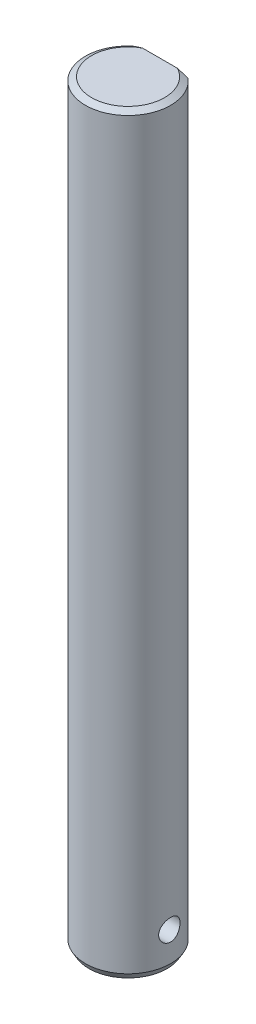
from build123d import *

# Parameters (mm, degrees)
SKETCH1_R             = 6
BOSS_EXTRUDE1_DEPTH   = 106
SKETCH2_W             = 13.926547721
SKETCH2_H             = 4.090447759
CUT_EXTRUDE1_DEPTH    = 10
SKETCH3_R             = 1.5
CUT_EXTRUDE2_DEPTH    = 10
CHAMFER1_SIZE         = 0.5
CHAMFER1_SIZE2        = 0.866025404
CHAMFER1_PART_2_SIZE  = 0.5
CHAMFER1_PART_2_SIZE2 = 0.866025404


with BuildPart() as part:
    # Sketch1 → Boss-Extrude1 (new body)
    with BuildSketch(Plane(origin=(0, 0, 0), x_dir=(1, 0, 0), z_dir=(0, 1, 0))):
        Circle(SKETCH1_R)
    extrude(amount=BOSS_EXTRUDE1_DEPTH)

    # Sketch2 → Cut-Extrude1 (cut)
    with BuildSketch(Plane(origin=(0, 106, 0), x_dir=(1, 0, 0), z_dir=(0, 1, 0))):
        with Locations((0.543038745, 6.545223879)):
            Rectangle(SKETCH2_W, SKETCH2_H)
    extrude(amount=-CUT_EXTRUDE1_DEPTH, mode=Mode.SUBTRACT)

    # Sketch3 → Cut-Extrude2 (cut, symmetric)
    with BuildSketch(Plane(origin=(0, 0, 0), x_dir=(0, 0, -1), z_dir=(1, 0, 0))):
        with Locations((0, 5)):
            Circle(SKETCH3_R)
    extrude(amount=CUT_EXTRUDE2_DEPTH, both=True, mode=Mode.SUBTRACT)

    # Chamfer1
    chamfer1_edges = [part.edges().sort_by_distance(p)[0] for p in [
        (-6, 0, 0),
    ]]
    chamfer1_side = [part.faces().sort_by_distance(p)[0] for p in [
        (0, 0, 0),
    ]]
    chamfer(chamfer1_edges, length=CHAMFER1_SIZE, length2=CHAMFER1_SIZE2, reference=chamfer1_side[0])

    # Chamfer1 part 2
    chamfer1_part_2_edges = [part.edges().sort_by_distance(p)[0] for p in [
        (-2.468626967, 106, 5.468626967),
    ]]
    chamfer1_part_2_side = [part.faces().sort_by_distance(p)[0] for p in [
        (-6, 53, 0),
    ]]
    chamfer(chamfer1_part_2_edges, length=CHAMFER1_PART_2_SIZE, length2=CHAMFER1_PART_2_SIZE2, reference=chamfer1_part_2_side[0])


solid = part.part
